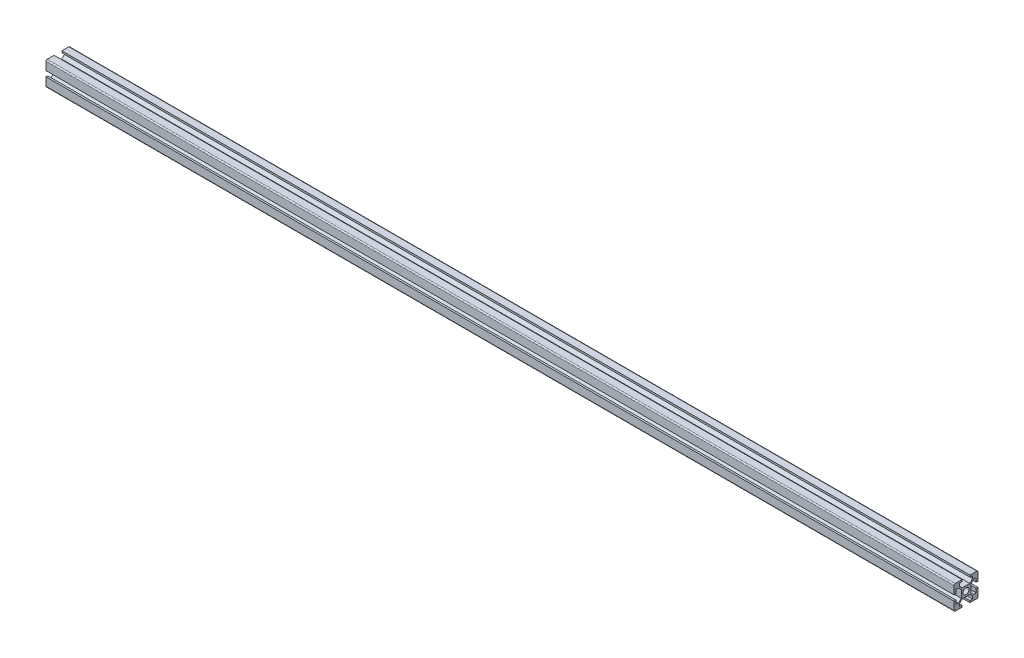
from build123d import *

# Parameters (mm, degrees)
SKETCH_11_R           = 2.5
F_20_X_20_X_2_1_DEPTH = 760


with BuildPart() as part:
    # 草图11 → 铝型材 20 X 20 X 2(1) (new body)
    with BuildSketch(Plane.YZ):
        with BuildLine():
            Line((-10, 9), (-10, 3.25))
            Line((-10, 3.25), (-8.5, 3.25))
            Line((-8.5, 3.25), (-8.5, 5.5))
            Line((-8.5, 5.5), (-6.348528137, 5.5))
            Line((-6.348528137, 5.5), (-4, 3.151471863))
            Line((-4, 3.151471863), (-4, -3.151471863))
            Line((-4, -3.151471863), (-6.348528137, -5.5))
            Line((-6.348528137, -5.5), (-8.5, -5.5))
            Line((-8.5, -5.5), (-8.5, -3.25))
            Line((-8.5, -3.25), (-10, -3.25))
            Line((-10, -3.25), (-10, -9))
            ThreePointArc((-10, -9), (-9.707106781, -9.707106781), (-9, -10))
            Line((-9, -10), (-2.25, -10))
            Line((-2.25, -10), (-2.25, -8.5))
            Line((-2.25, -8.5), (-5.5, -8.5))
            Line((-5.5, -8.5), (-5.5, -6.348528137))
            Line((-5.5, -6.348528137), (-3.151471863, -4))
            Line((-3.151471863, -4), (3.151471863, -4))
            Line((3.151471863, -4), (5.5, -6.348528137))
            Line((5.5, -6.348528137), (5.5, -8.5))
            Line((5.5, -8.5), (2.25, -8.5))
            Line((2.25, -8.5), (2.25, -10))
            Line((2.25, -10), (9, -10))
            ThreePointArc((9, -10), (9.707106781, -9.707106781), (10, -9))
            Line((10, -9), (10, -3.25))
            Line((10, -3.25), (8.5, -3.25))
            Line((8.5, -3.25), (8.5, -5.5))
            Line((8.5, -5.5), (6.348528137, -5.5))
            Line((6.348528137, -5.5), (4, -3.151471863))
            Line((4, -3.151471863), (4, 3.151471863))
            Line((4, 3.151471863), (6.348528137, 5.5))
            Line((6.348528137, 5.5), (8.5, 5.5))
            Line((8.5, 5.5), (8.5, 3.25))
            Line((8.5, 3.25), (10, 3.25))
            Line((10, 3.25), (10, 9))
            ThreePointArc((10, 9), (9.707106781, 9.707106781), (9, 10))
            Line((9, 10), (2.25, 10))
            Line((2.25, 10), (2.25, 8.5))
            Line((2.25, 8.5), (5.5, 8.5))
            Line((5.5, 8.5), (5.5, 6.348528137))
            Line((5.5, 6.348528137), (3.151471863, 4))
            Line((3.151471863, 4), (-3.151471863, 4))
            Line((-3.151471863, 4), (-5.5, 6.348528137))
            Line((-5.5, 6.348528137), (-5.5, 8.5))
            Line((-5.5, 8.5), (-2.25, 8.5))
            Line((-2.25, 8.5), (-2.25, 10))
            Line((-2.25, 10), (-9, 10))
            ThreePointArc((-9, 10), (-9.707106781, 9.707106781), (-10, 9))
        make_face()
        Circle(SKETCH_11_R, mode=Mode.SUBTRACT)
    extrude(amount=F_20_X_20_X_2_1_DEPTH)


solid = part.part
